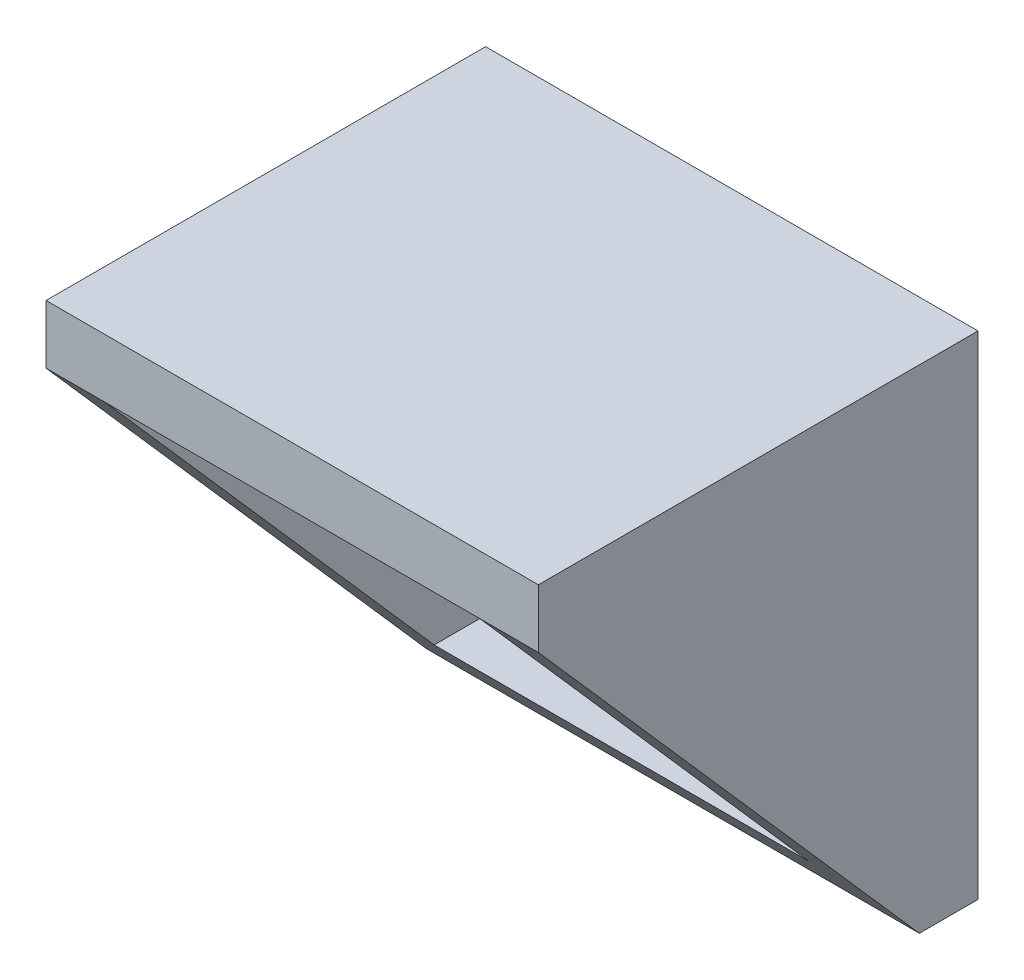
from build123d import *

# Parameters (mm, degrees)
SKETCH1_W           = 16.8
SKETCH1_H           = 16.8
SKETCH1_W_2         = 12.8
SKETCH1_H_2         = 12.8
BOSS_EXTRUDE1_DEPTH = 15
CUT_EXTRUDE1_DEPTH  = 17.8


with BuildPart() as part:
    # Sketch1 → Boss-Extrude1 (new body)
    with BuildSketch(Plane.XY):
        Rectangle(SKETCH1_W, SKETCH1_H)
        Rectangle(SKETCH1_W_2, SKETCH1_H_2, mode=Mode.SUBTRACT)
    extrude(amount=BOSS_EXTRUDE1_DEPTH)

    # Sketch2 → Cut-Extrude1 (cut, through all)
    with BuildSketch(Plane(origin=(8.4, 0, 0), x_dir=(0, 0, -1), z_dir=(1, 0, 0))):
        Polygon((-15, 6.4), (-2, -8.4), (-15, -8.4), align=None)
    extrude(amount=-CUT_EXTRUDE1_DEPTH, mode=Mode.SUBTRACT)


solid = part.part
